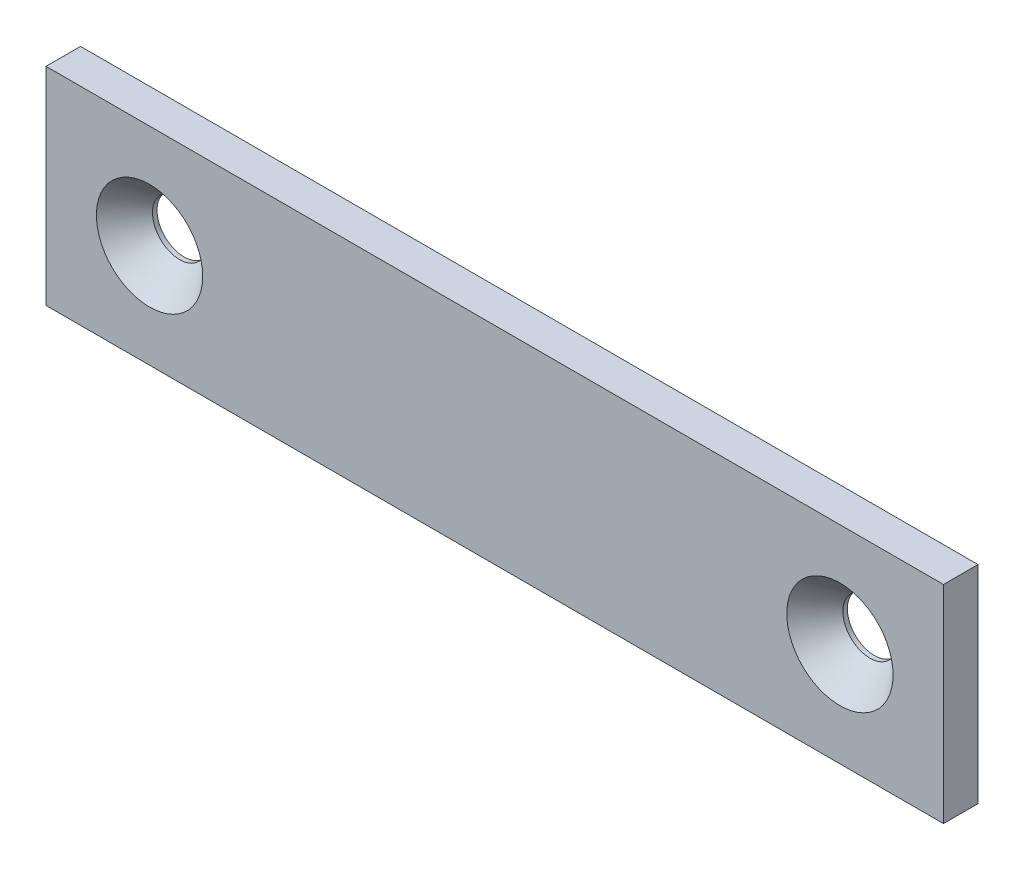
from build123d import *

# Parameters (mm, degrees)
SKETCH1_W                                    = 82.55
SKETCH1_H                                    = 19.05
EXTRUDE1_DEPTH                               = 1.5875
CSK_FOR_10_FLAT_HEAD_MACHINE_SCREW1_AT_COUNT = 2
CSK_FOR_10_FLAT_HEAD_MACHINE_SCREW1_AT_PITCH = 63.5


with BuildPart() as part:
    # Sketch1 → Extrude1 (new body, symmetric)
    with BuildSketch(Plane.XY):
        Rectangle(SKETCH1_W, SKETCH1_H)
    extrude(amount=EXTRUDE1_DEPTH, both=True)

    # Sketch2 → CSK for #10 Flat Head Machine Screw1 (revolve, cut)
    with BuildSketch(Plane(origin=(-31.75, 0, 1.5875), x_dir=(0, -1, 0), z_dir=(1, 0, 0))):
        Polygon((0, 0), (0, 3.175), (2.4892, 3.175), (2.4892, 2.761229288), (4.8895, 0), align=None)
    csk_for_10_flat_head_machine_screw1 = revolve(axis=Axis((-31.75, 0, 7.9375), (0, 0, -1)), mode=Mode.SUBTRACT)

    # CSK for #10 Flat Head Machine Screw1 at: CSK for #10 Flat Head Machine Screw1 ×2
    with Locations(*[(i * CSK_FOR_10_FLAT_HEAD_MACHINE_SCREW1_AT_PITCH, 0, 0) for i in range(1, CSK_FOR_10_FLAT_HEAD_MACHINE_SCREW1_AT_COUNT)]):
        add(csk_for_10_flat_head_machine_screw1, mode=Mode.SUBTRACT)


solid = part.part
